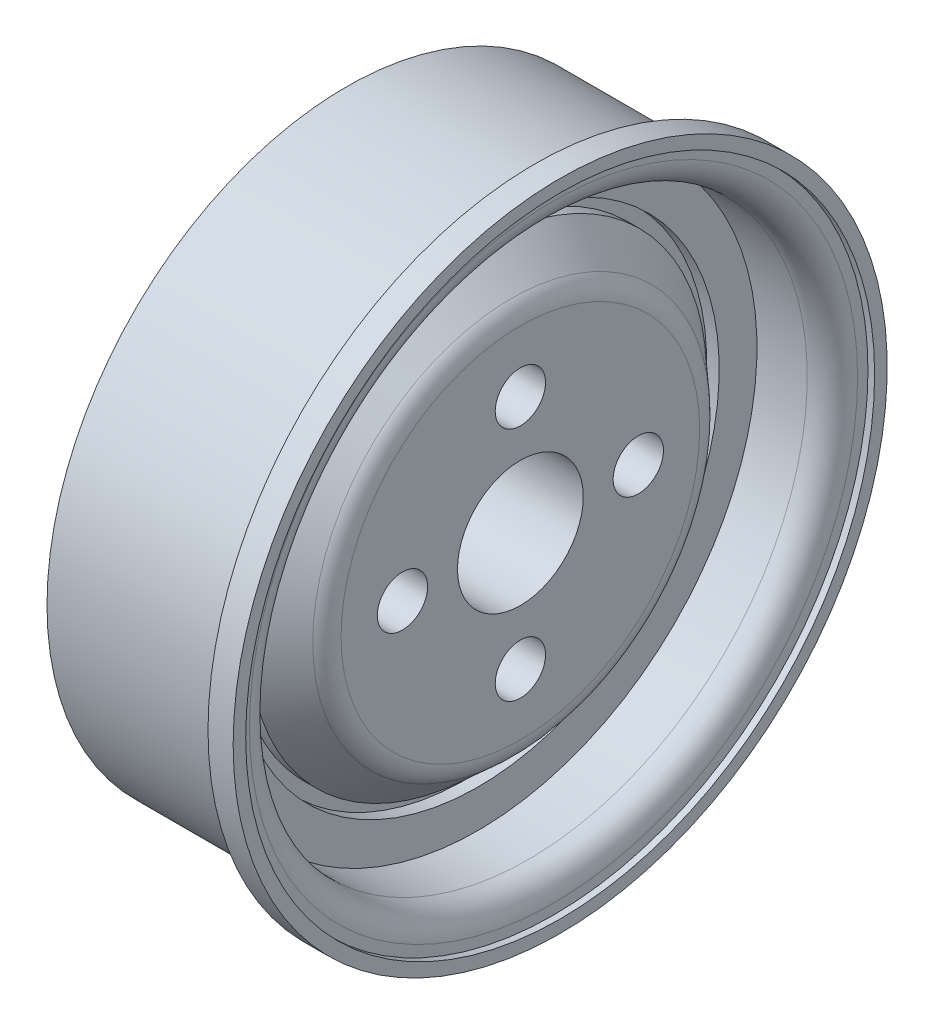
from build123d import *

# Parameters (mm, degrees)
FILLET1_R          = 1
SKETCH2_R          = 2.5
SKETCH2_R_2        = 1
CUT_EXTRUDE1_DEPTH = 5


with BuildPart() as part:
    # Sketch1 → Revolve1 (revolve)
    with BuildSketch(Plane(origin=(0, 0, 0), x_dir=(1, 0, 0), z_dir=(0, 1, 0))):
        with BuildLine():
            Line((5.429394359, 13), (4.429394359, 13))
            Line((4.429394359, 13), (4.429394359, 11.9))
            Line((4.429394359, 11.9), (-3.070605641, 11.9))
            Line((-3.070605641, 11.9), (-3.070605641, 9.9))
            Line((-3.070605641, 9.9), (0.164577559, 9.9))
            Line((0.164577559, 9.9), (0.164577559, 7.086841674))
            Line((0.164577559, 7.086841674), (0.164577559, 3.25))
            Line((0.164577559, 3.25), (-4.835422441, 3.25))
            Line((-4.835422441, 3.25), (-4.835422441, 1.25))
            Line((-4.835422441, 1.25), (1.847087525, 1.25))
            Line((1.847087525, 1.25), (1.847087525, 0))
            Line((1.847087525, 0), (3.847087525, 0))
            Line((3.847087525, 0), (3.847087525, 7.12829034))
            ThreePointArc((3.847087525, 7.12829034), (3.753395312, 7.550908601), (3.489875135, 7.894334783))
            Line((3.489875135, 7.894334783), (2.164577559, 9.086841674))
            Line((2.164577559, 9.086841674), (1.664577559, 9.086841674))
            Line((1.664577559, 9.086841674), (1.664577559, 9.586841674))
            Line((1.664577559, 9.586841674), (2.164577559, 9.586841674))
            Line((2.164577559, 9.586841674), (2.164577559, 11.086841674))
            Line((2.164577559, 11.086841674), (5.164577559, 11.086841674))
            Line((5.164577559, 11.086841674), (5.164577559, 12.5))
            Line((5.164577559, 12.5), (5.429394359, 12.5))
            Line((5.429394359, 12.5), (5.429394359, 13))
        make_face()
    revolve(axis=Axis((-7.139696802, 0, 0), (1, 0, 0)))

    # Fillet1
    fillet1_edges = [part.edges().sort_by_distance(p)[0] for p in [
        (5.164577559, 0, 11.086841674),
    ]]
    fillet(fillet1_edges, radius=FILLET1_R)

    # Sketch2 → Cut-Extrude1 (cut, symmetric)
    with BuildSketch(Plane(origin=(3.847087525, 0, 0), x_dir=(0, 0, -1), z_dir=(1, 0, 0))):
        Circle(SKETCH2_R)
        with Locations((0, 4.68715006)):
            Circle(SKETCH2_R_2)
        with Locations((4.68715006, 0)):
            Circle(SKETCH2_R_2)
        with Locations((0, -4.68715006)):
            Circle(SKETCH2_R_2)
        with Locations((-4.68715006, 0)):
            Circle(SKETCH2_R_2)
    extrude(amount=CUT_EXTRUDE1_DEPTH, both=True, mode=Mode.SUBTRACT)


solid = part.part
